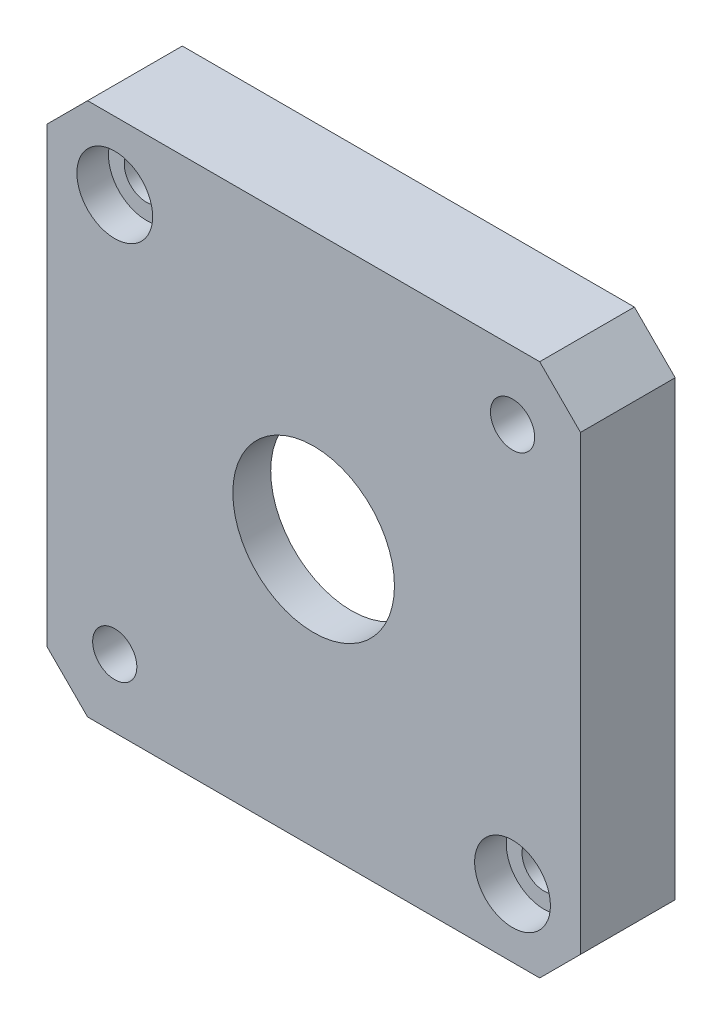
from build123d import *

# Parameters (mm, degrees)
SKETCH1_R           = 18.5
SKETCH1_R_2         = 1.75
BOSS_EXTRUDE1_DEPTH = 4.5
SKETCH2_R           = 6.4
SKETCH2_R_2         = 1.75
BOSS_EXTRUDE2_DEPTH = 3
SKETCH3_R           = 3
CUT_EXTRUDE1_DEPTH  = 2.5


with BuildPart() as part:
    # Sketch1 → Boss-Extrude1 (new body)
    with BuildSketch(Plane.XY):
        Polygon((-12.327463607, 17.616562478), (-12.327463607, -18.183437522), (-9.095169285, -21.415731844), (26.704830715, -21.415731844), (29.937125036, -18.183437522), (29.937125036, 17.616562478), (26.704830715, 20.848856799), (-9.095169285, 20.848856799), align=None)
        with Locations((8.804830715, -0.283437522)):
            Circle(SKETCH1_R, mode=Mode.SUBTRACT)
        with Locations((-6.945169285, 15.466562478)):
            Circle(SKETCH1_R_2, mode=Mode.SUBTRACT)
        with Locations((-6.945169285, -16.033437522)):
            Circle(SKETCH1_R_2, mode=Mode.SUBTRACT)
        with Locations((24.554830715, -16.033437522)):
            Circle(SKETCH1_R_2, mode=Mode.SUBTRACT)
        with Locations((24.554830715, 15.466562478)):
            Circle(SKETCH1_R_2, mode=Mode.SUBTRACT)
    extrude(amount=BOSS_EXTRUDE1_DEPTH)

    # Sketch2 → Boss-Extrude2 (add)
    with BuildSketch(Plane.XY.offset(4.5)):
        Polygon((-12.327463607, 17.616562478), (-9.095169285, 20.848856799), (26.704830715, 20.848856799), (29.937125036, 17.616562478), (29.937125036, -18.183437522), (26.704830715, -21.415731844), (-9.095169285, -21.415731844), (-12.327463607, -18.183437522), align=None)
        with Locations((8.804830715, -0.283437522)):
            Circle(SKETCH2_R, mode=Mode.SUBTRACT)
        with Locations((-6.945169285, 15.466562478)):
            Circle(SKETCH2_R_2, mode=Mode.SUBTRACT)
        with Locations((24.554830715, 15.466562478)):
            Circle(SKETCH2_R_2, mode=Mode.SUBTRACT)
        with Locations((24.554830715, -16.033437522)):
            Circle(SKETCH2_R_2, mode=Mode.SUBTRACT)
        with Locations((-6.945169285, -16.033437522)):
            Circle(SKETCH2_R_2, mode=Mode.SUBTRACT)
    extrude(amount=BOSS_EXTRUDE2_DEPTH)

    # Sketch3 → Cut-Extrude1 (cut)
    with BuildSketch(Plane.XY.offset(7.5)):
        with Locations((-6.945169285, 15.466562478)):
            Circle(SKETCH3_R)
        with Locations((24.554830715, -16.033437522)):
            Circle(SKETCH3_R)
    extrude(amount=-CUT_EXTRUDE1_DEPTH, mode=Mode.SUBTRACT)


solid = part.part
